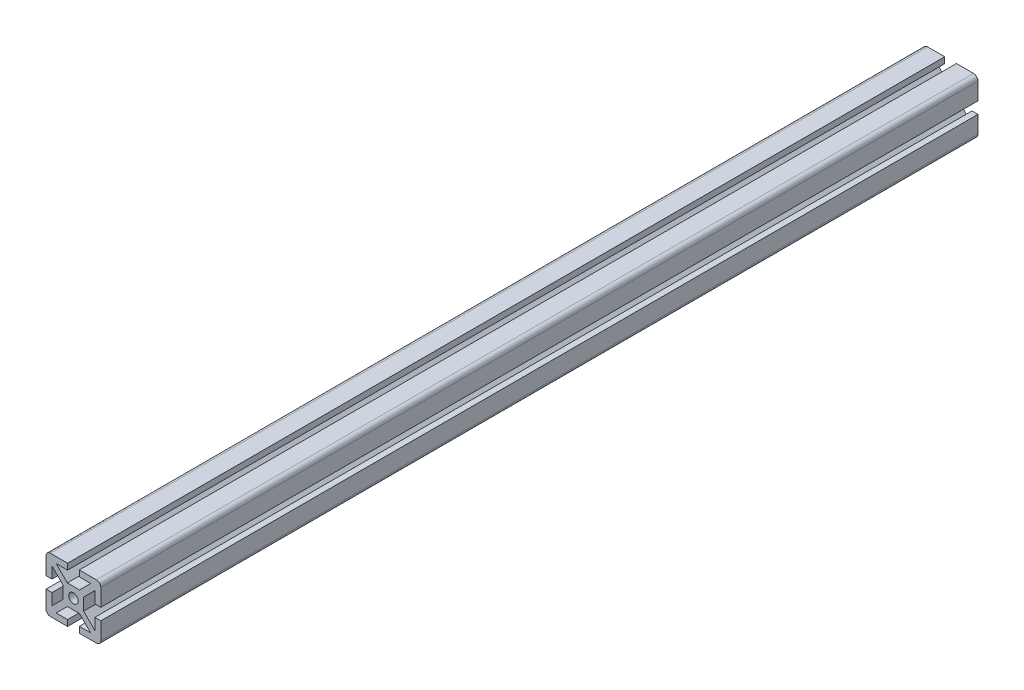
from build123d import *

# Parameters (mm, degrees)
SKETCH1_R      = 3.2639
FINALCUT_DEPTH = 609.6


with BuildPart() as part:
    # Sketch1 → FinalCut (new body)
    with BuildSketch(Plane.XY):
        with BuildLine():
            Line((-7.112, 0), (-7.112, 4.238318041))
            Line((-7.112, 4.238318041), (-14.8844, 12.010718041))
            Line((-14.8844, 12.010718041), (-14.8844, 4.064))
            Line((-14.8844, 4.064), (-19.05, 4.064))
            Line((-19.05, 4.064), (-19.05, 16.002))
            ThreePointArc((-19.05, 16.002), (-18.157261469, 18.157261469), (-16.002, 19.05))
            Line((-16.002, 19.05), (-4.064, 19.05))
            Line((-4.064, 19.05), (-4.064, 14.8844))
            Line((-4.064, 14.8844), (-12.010718041, 14.8844))
            Line((-12.010718041, 14.8844), (-4.238318041, 7.112))
            Line((-4.238318041, 7.112), (0, 7.112))
            Line((0, 7.112), (4.238318041, 7.112))
            Line((4.238318041, 7.112), (12.010718041, 14.8844))
            Line((12.010718041, 14.8844), (4.064, 14.8844))
            Line((4.064, 14.8844), (4.064, 19.05))
            Line((4.064, 19.05), (16.002, 19.05))
            ThreePointArc((16.002, 19.05), (18.157261469, 18.157261469), (19.05, 16.002))
            Line((19.05, 16.002), (19.05, 4.064))
            Line((19.05, 4.064), (14.8844, 4.064))
            Line((14.8844, 4.064), (14.8844, 12.010718041))
            Line((14.8844, 12.010718041), (7.112, 4.238318041))
            Line((7.112, 4.238318041), (7.112, 0))
            Line((7.112, 0), (7.112, -4.238318041))
            Line((7.112, -4.238318041), (14.8844, -12.010718041))
            Line((14.8844, -12.010718041), (14.8844, -4.064))
            Line((14.8844, -4.064), (19.05, -4.064))
            Line((19.05, -4.064), (19.05, -16.002))
            ThreePointArc((19.05, -16.002), (18.157261469, -18.157261469), (16.002, -19.05))
            Line((16.002, -19.05), (4.064, -19.05))
            Line((4.064, -19.05), (4.064, -14.8844))
            Line((4.064, -14.8844), (12.010718041, -14.8844))
            Line((12.010718041, -14.8844), (4.238318041, -7.112))
            Line((4.238318041, -7.112), (0, -7.112))
            Line((0, -7.112), (-4.238318041, -7.112))
            Line((-4.238318041, -7.112), (-12.010718041, -14.8844))
            Line((-12.010718041, -14.8844), (-4.064, -14.8844))
            Line((-4.064, -14.8844), (-4.064, -19.05))
            Line((-4.064, -19.05), (-16.002, -19.05))
            ThreePointArc((-16.002, -19.05), (-18.157261469, -18.157261469), (-19.05, -16.002))
            Line((-19.05, -16.002), (-19.05, -4.064))
            Line((-19.05, -4.064), (-14.8844, -4.064))
            Line((-14.8844, -4.064), (-14.8844, -12.010718041))
            Line((-14.8844, -12.010718041), (-7.112, -4.238318041))
            Line((-7.112, -4.238318041), (-7.112, 0))
        make_face()
        Circle(SKETCH1_R, mode=Mode.SUBTRACT)
    extrude(amount=-FINALCUT_DEPTH)


solid = part.part
